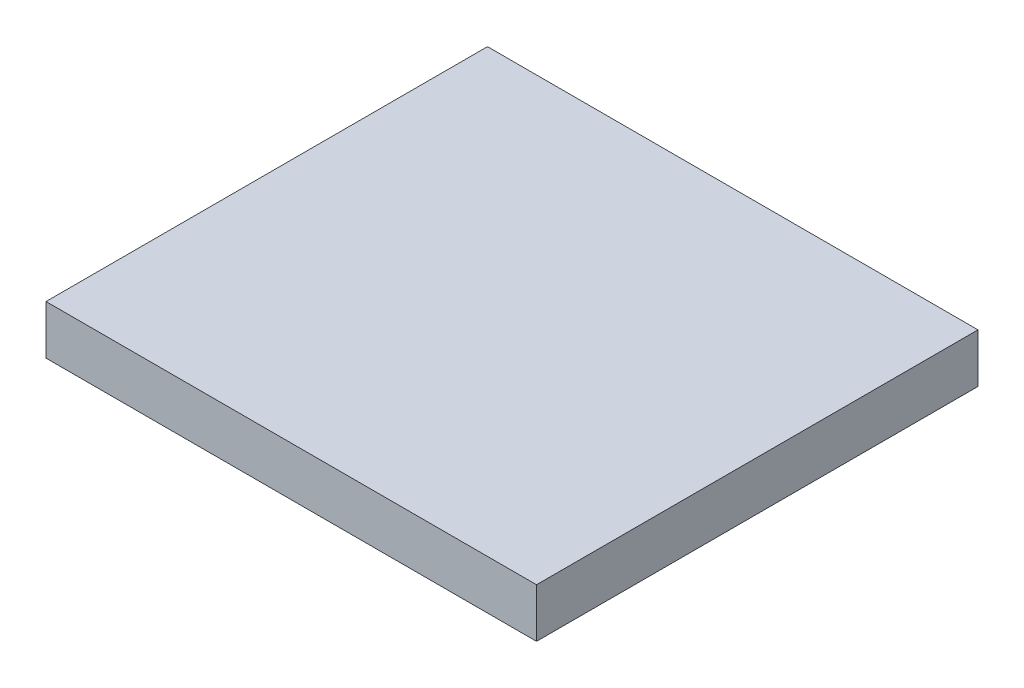
from build123d import *

# Parameters (mm, degrees)
SKETCH1_W           = 100
SKETCH1_H           = 90
BOSS_EXTRUDE1_DEPTH = 10


with BuildPart() as part:
    # Sketch1 → Boss-Extrude1 (new body)
    with BuildSketch(Plane(origin=(0, 0, 0), x_dir=(1, 0, 0), z_dir=(0, 1, 0))):
        Rectangle(SKETCH1_W, SKETCH1_H)
    extrude(amount=BOSS_EXTRUDE1_DEPTH)


solid = part.part
